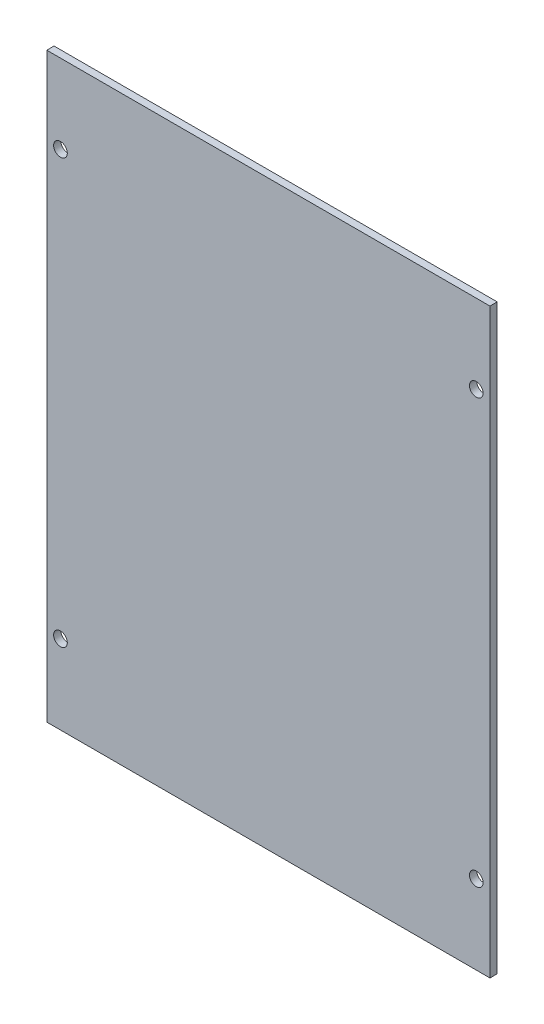
from build123d import *

# Parameters (mm, degrees)
SKETCH1_W             = 146.05
SKETCH1_H             = 191.77
BOSS_EXTRUDE1_DEPTH   = 1.1938
F_8_CLEARANCE_HOLE1_D = 4.4958


with BuildPart() as part:
    # Sketch1 → Boss-Extrude1 (new body, symmetric)
    with BuildSketch(Plane.XY):
        Rectangle(SKETCH1_W, SKETCH1_H)
    extrude(amount=BOSS_EXTRUDE1_DEPTH, both=True)

    # #8 Clearance Hole1 (through all)
    with Locations(Plane(origin=(68.5165, 69.85, 1.1938), x_dir=(1, 0, 0), z_dir=(0, 0, 1))):
        with Locations((0, 0), (-137.033, 0), (-137.033, -139.7), (0, -139.7)):
            Hole(F_8_CLEARANCE_HOLE1_D / 2)


solid = part.part
